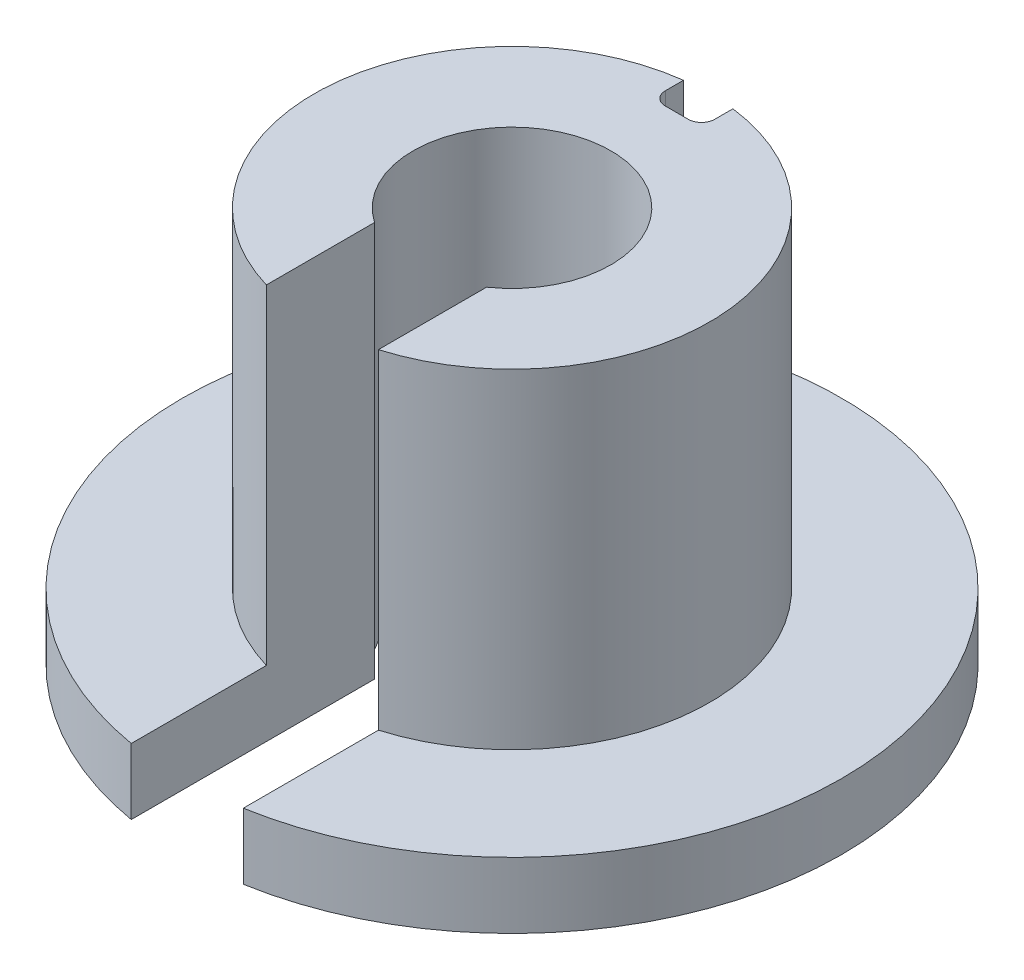
from build123d import *

# Parameters (mm, degrees)
BOSS_EXTRUDE1_DEPTH = 12
BOSS_EXTRUDE2_DEPTH = 2
CUT_EXTRUDE1_DEPTH  = 10
FILLET1_R           = 0.4


with BuildPart() as part:
    # Sketch1 → Boss-Extrude1 (new body)
    with BuildSketch(Plane(origin=(0, 0, 0), x_dir=(1, 0, 0), z_dir=(0, 1, 0))):
        with BuildLine():
            Line((-1.7, -2.471841419), (-1.7, -5.754128952))
            ThreePointArc((-1.7, -5.754128952), (0, 6), (1.7, -5.754128952))
            Line((1.7, -5.754128952), (1.7, -2.471841419))
            ThreePointArc((1.7, -2.471841419), (0, 3), (-1.7, -2.471841419))
        make_face()
    extrude(amount=BOSS_EXTRUDE1_DEPTH)

    # Sketch2 → Boss-Extrude2 (add)
    with BuildSketch(Plane.XZ):
        with BuildLine():
            Line((-1.7, 5.754128952), (-1.7, 9.854440623))
            ThreePointArc((-1.7, 9.854440623), (0, -10), (1.7, 9.854440623))
            Line((1.7, 9.854440623), (1.7, 5.754128952))
            ThreePointArc((1.7, 5.754128952), (0, -6), (-1.7, 5.754128952))
        make_face()
    extrude(amount=-BOSS_EXTRUDE2_DEPTH)

    # Sketch3 → Cut-Extrude1 (cut)
    with BuildSketch(Plane(origin=(0, 12, 0), x_dir=(1, 0, 0), z_dir=(0, 1, 0))):
        with BuildLine():
            Line((-0.75, 5.95294045), (-0.75, 5))
            Line((-0.75, 5), (0.75, 5))
            Line((0.75, 5), (0.75, 5.95294045))
            ThreePointArc((0.75, 5.95294045), (0, 6), (-0.75, 5.95294045))
        make_face()
    extrude(amount=-CUT_EXTRUDE1_DEPTH, mode=Mode.SUBTRACT)

    # Fillet1
    fillet1_edges = [part.edges().sort_by_distance(p)[0] for p in [
        (-0.75, 7, -5),
        (0.75, 7, -5),
    ]]
    fillet(fillet1_edges, radius=FILLET1_R)


solid = part.part
